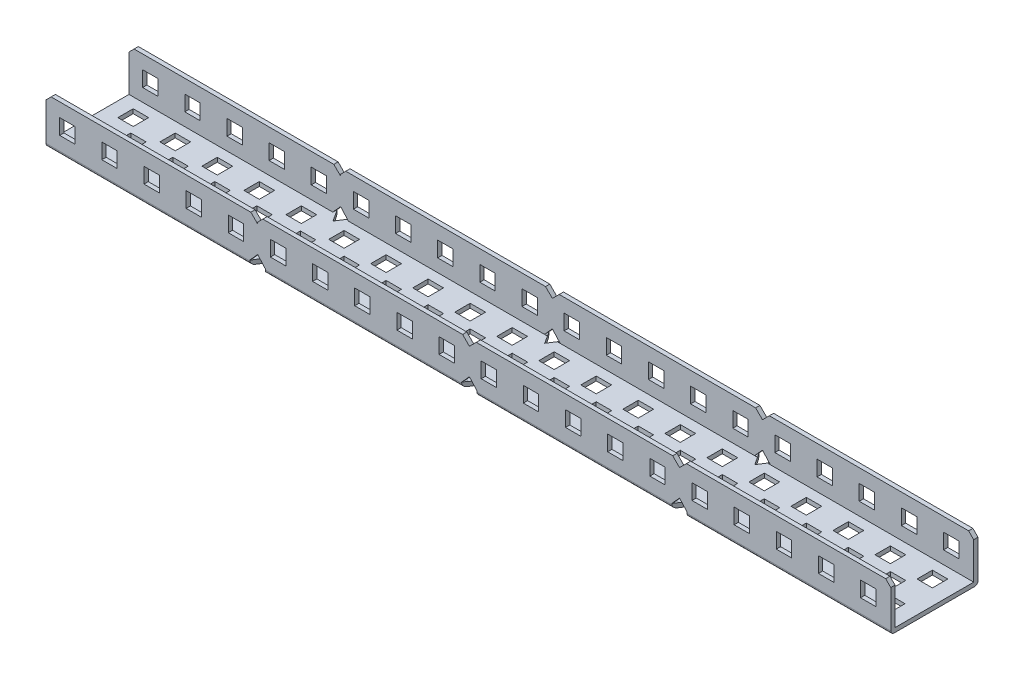
from build123d import *

# Parameters (mm, degrees)
SKETCH1_W           = 191
SKETCH1_H           = 25.5
BOSS_EXTRUDE1_DEPTH = 1.25
SKETCH2_W           = 191
SKETCH2_H           = 1.25
BOSS_EXTRUDE2_DEPTH = 12.25
SKETCH3_W           = 4.5
SKETCH3_H           = 4.5
CUT_EXTRUDE1_DEPTH  = 12.25
CUT_EXTRUDE2_DEPTH  = 1.3
CUT_EXTRUDE4_DEPTH  = 48.3
CUT_EXTRUDE5_DEPTH  = 48.3
FILLET1_R           = 1
SKETCH8_W           = 4.5
SKETCH8_H           = 4.5
BOSS_EXTRUDE3_DEPTH = 1.25
SKETCH9_W           = 2.25
SKETCH9_H           = 4.5
CUT_EXTRUDE6_DEPTH  = 1.25
BOSS_EXTRUDE4_DEPTH = 25.5
SKETCH11_W          = 23
SKETCH11_H          = 12.25
CUT_EXTRUDE7_DEPTH  = 284.5
SKETCH12_W          = 4.5
SKETCH12_H          = 4.5
CUT_EXTRUDE8_DEPTH  = 284.5
CUT_EXTRUDE9_DEPTH  = 284.5
FILLET2_R           = 1
SKETCH14_W          = 5.918571429
SKETCH14_H          = 1
SKETCH14_W_2        = 4.5
SKETCH14_H_2        = 4.5
CUT_EXTRUDE10_DEPTH = 284.5
CUT_EXTRUDE11_DEPTH = 284.5
SKETCH16_W          = 2.581428571
SKETCH16_H          = 4.5
BOSS_EXTRUDE5_DEPTH = 1.25


with BuildPart() as part:
    # Sketch1 → Boss-Extrude1 (new body)
    with BuildSketch(Plane(origin=(0, 0, 0), x_dir=(1, 0, 0), z_dir=(0, 1, 0))):
        with Locations((95.5, 12.75)):
            Rectangle(SKETCH1_W, SKETCH1_H)
    extrude(amount=BOSS_EXTRUDE1_DEPTH)

    # Sketch2 → Boss-Extrude2 (add)
    with BuildSketch(Plane(origin=(0, 1.25, 0), x_dir=(1, 0, 0), z_dir=(0, 1, 0))):
        with Locations((95.5, 24.875)):
            Rectangle(SKETCH2_W, SKETCH2_H)
        with Locations((95.5, 0.625)):
            Rectangle(SKETCH2_W, SKETCH2_H)
    extrude(amount=BOSS_EXTRUDE2_DEPTH)

    # Sketch3 → Cut-Extrude1 (cut)
    with BuildSketch(Plane(origin=(0, 0, 0), x_dir=(-1, 0, 0), z_dir=(0, -1, 0))):
        with Locations((-6.25, 6.5)):
            Rectangle(SKETCH3_W, SKETCH3_H)
        with Locations((-6.25, 19)):
            Rectangle(SKETCH3_W, SKETCH3_H)
        with Locations((-18.535714286, 6.5)):
            Rectangle(SKETCH3_W, SKETCH3_H)
        with Locations((-12.75, 12.5)):
            Rectangle(SKETCH3_W, SKETCH3_H)
        with Locations((-18.535714286, 19)):
            Rectangle(SKETCH3_W, SKETCH3_H)
        with Locations((-25.035714286, 12.5)):
            Rectangle(SKETCH3_W, SKETCH3_H)
        with Locations((-30.821428571, 6.5)):
            Rectangle(SKETCH3_W, SKETCH3_H)
        with Locations((-30.821428571, 19)):
            Rectangle(SKETCH3_W, SKETCH3_H)
        with Locations((-37.321428571, 12.5)):
            Rectangle(SKETCH3_W, SKETCH3_H)
        with Locations((-43.107142857, 6.5)):
            Rectangle(SKETCH3_W, SKETCH3_H)
        with Locations((-43.107142857, 19)):
            Rectangle(SKETCH3_W, SKETCH3_H)
        with Locations((-49.607142857, 12.5)):
            Rectangle(SKETCH3_W, SKETCH3_H)
        with Locations((-55.392857143, 6.5)):
            Rectangle(SKETCH3_W, SKETCH3_H)
        with Locations((-55.392857143, 19)):
            Rectangle(SKETCH3_W, SKETCH3_H)
        with Locations((-61.892857143, 12.5)):
            Rectangle(SKETCH3_W, SKETCH3_H)
        with Locations((-67.678571429, 6.5)):
            Rectangle(SKETCH3_W, SKETCH3_H)
        with Locations((-67.678571429, 19)):
            Rectangle(SKETCH3_W, SKETCH3_H)
        with Locations((-74.178571429, 12.5)):
            Rectangle(SKETCH3_W, SKETCH3_H)
        with Locations((-79.964285714, 6.5)):
            Rectangle(SKETCH3_W, SKETCH3_H)
        with Locations((-79.964285714, 19)):
            Rectangle(SKETCH3_W, SKETCH3_H)
        with Locations((-86.464285714, 12.5)):
            Rectangle(SKETCH3_W, SKETCH3_H)
        with Locations((-92.25, 6.5)):
            Rectangle(SKETCH3_W, SKETCH3_H)
        with Locations((-92.25, 19)):
            Rectangle(SKETCH3_W, SKETCH3_H)
        with Locations((-98.75, 12.5)):
            Rectangle(SKETCH3_W, SKETCH3_H)
        with Locations((-104.535714286, 6.5)):
            Rectangle(SKETCH3_W, SKETCH3_H)
        with Locations((-104.535714286, 19)):
            Rectangle(SKETCH3_W, SKETCH3_H)
        with Locations((-111.035714286, 12.5)):
            Rectangle(SKETCH3_W, SKETCH3_H)
        with Locations((-116.821428571, 6.5)):
            Rectangle(SKETCH3_W, SKETCH3_H)
        with Locations((-116.821428571, 19)):
            Rectangle(SKETCH3_W, SKETCH3_H)
        with Locations((-123.321428571, 12.5)):
            Rectangle(SKETCH3_W, SKETCH3_H)
        with Locations((-129.107142857, 6.5)):
            Rectangle(SKETCH3_W, SKETCH3_H)
        with Locations((-129.107142857, 19)):
            Rectangle(SKETCH3_W, SKETCH3_H)
        with Locations((-135.607142857, 12.5)):
            Rectangle(SKETCH3_W, SKETCH3_H)
        with Locations((-141.392857143, 6.5)):
            Rectangle(SKETCH3_W, SKETCH3_H)
        with Locations((-141.392857143, 19)):
            Rectangle(SKETCH3_W, SKETCH3_H)
        with Locations((-147.892857143, 12.5)):
            Rectangle(SKETCH3_W, SKETCH3_H)
        with Locations((-153.678571429, 6.5)):
            Rectangle(SKETCH3_W, SKETCH3_H)
        with Locations((-153.678571429, 19)):
            Rectangle(SKETCH3_W, SKETCH3_H)
        with Locations((-160.178571429, 12.5)):
            Rectangle(SKETCH3_W, SKETCH3_H)
        with Locations((-165.964285714, 6.5)):
            Rectangle(SKETCH3_W, SKETCH3_H)
        with Locations((-165.964285714, 19)):
            Rectangle(SKETCH3_W, SKETCH3_H)
        with Locations((-172.464285714, 12.5)):
            Rectangle(SKETCH3_W, SKETCH3_H)
        with Locations((-178.25, 6.5)):
            Rectangle(SKETCH3_W, SKETCH3_H)
        with Locations((-178.25, 19)):
            Rectangle(SKETCH3_W, SKETCH3_H)
        with Locations((-184.75, 12.5)):
            Rectangle(SKETCH3_W, SKETCH3_H)
    extrude(amount=-CUT_EXTRUDE1_DEPTH, mode=Mode.SUBTRACT)

    # Sketch4 → Cut-Extrude2 (cut)
    with BuildSketch(Plane.XZ):
        Polygon((61.892857143, -3.5), (59.642857143, 0), (64.142857143, 0), align=None)
        Polygon((123.321428571, -3.5), (121.071428571, 0), (125.571428571, 0), align=None)
        Polygon((121.071428571, -25.5), (125.571428571, -25.5), (123.321428571, -22), align=None)
        Polygon((59.642857143, -25.5), (64.142857143, -25.5), (61.892857143, -22), align=None)
    extrude(amount=-CUT_EXTRUDE2_DEPTH, mode=Mode.SUBTRACT)

    # Sketch6 → Cut-Extrude4 (cut)
    with BuildSketch(Plane(origin=(0, 0, -25.5), x_dir=(-1, 0, 0), z_dir=(0, 0, -1))):
        Polygon((-123.321428571, 3.8), (-121.071428571, 1.3), (-125.571428571, 1.3), align=None)
        Polygon((-61.892857143, 3.8), (-59.642857143, 1.3), (-64.142857143, 1.3), align=None)
        Polygon((-125.321428571, 13.5), (-121.321428571, 13.5), (-123.321428571, 11.5), align=None)
        Polygon((-63.892857143, 13.5), (-59.892857143, 13.5), (-61.892857143, 11.5), align=None)
    extrude(amount=-CUT_EXTRUDE4_DEPTH, mode=Mode.SUBTRACT)

    # Sketch7 → Cut-Extrude5 (cut)
    with BuildSketch(Plane(origin=(0, 0, -25.5), x_dir=(-1, 0, 0), z_dir=(0, 0, -1))):
        Polygon((-191, 13.5), (-191, 12), (-189.5, 13.5), align=None)
        Polygon((-1.5, 13.5), (0, 13.5), (0, 12), align=None)
    extrude(amount=-CUT_EXTRUDE5_DEPTH, mode=Mode.SUBTRACT)

    # Fillet1
    fillet1_edges = [part.edges().sort_by_distance(p)[0] for p in [
        (158.285714286, 0, -25.5),
        (29.821428571, 0, 0),
        (92.607142857, 0, 0),
        (92.607142857, 0, -25.5),
        (29.821428571, 0, -25.5),
        (158.285714286, 0, 0),
    ]]
    fillet(fillet1_edges, radius=FILLET1_R)

    # Sketch8 → Boss-Extrude3 (add)
    with BuildSketch(Plane.XZ):
        Polygon((-2.25, -25.5), (0, -22), (0, -14.75), (-2.25, -14.75), (-2.25, -10.25), (0, -10.25), (0, -3.5), (-2.25, 0), (-61.892857143, 0), (-61.892857143, -25.5), align=None)
        with Locations((-55.642857143, -19)):
            Rectangle(SKETCH8_W, SKETCH8_H, mode=Mode.SUBTRACT)
        with Locations((-43.357142857, -19)):
            Rectangle(SKETCH8_W, SKETCH8_H, mode=Mode.SUBTRACT)
        with Locations((-31.071428571, -19)):
            Rectangle(SKETCH8_W, SKETCH8_H, mode=Mode.SUBTRACT)
        with Locations((-18.785714286, -19)):
            Rectangle(SKETCH8_W, SKETCH8_H, mode=Mode.SUBTRACT)
        with Locations((-6.5, -19)):
            Rectangle(SKETCH8_W, SKETCH8_H, mode=Mode.SUBTRACT)
        with Locations((-49.142857143, -12.5)):
            Rectangle(SKETCH8_W, SKETCH8_H, mode=Mode.SUBTRACT)
        with Locations((-36.857142857, -12.5)):
            Rectangle(SKETCH8_W, SKETCH8_H, mode=Mode.SUBTRACT)
        with Locations((-55.642857143, -6.5)):
            Rectangle(SKETCH8_W, SKETCH8_H, mode=Mode.SUBTRACT)
        with Locations((-43.357142857, -6.5)):
            Rectangle(SKETCH8_W, SKETCH8_H, mode=Mode.SUBTRACT)
        with Locations((-31.071428571, -6.5)):
            Rectangle(SKETCH8_W, SKETCH8_H, mode=Mode.SUBTRACT)
        with Locations((-24.571428571, -12.5)):
            Rectangle(SKETCH8_W, SKETCH8_H, mode=Mode.SUBTRACT)
        with Locations((-12.285714286, -12.5)):
            Rectangle(SKETCH8_W, SKETCH8_H, mode=Mode.SUBTRACT)
        with Locations((-18.785714286, -6.5)):
            Rectangle(SKETCH8_W, SKETCH8_H, mode=Mode.SUBTRACT)
        with Locations((-6.5, -6.5)):
            Rectangle(SKETCH8_W, SKETCH8_H, mode=Mode.SUBTRACT)
    extrude(amount=-BOSS_EXTRUDE3_DEPTH)

    # Sketch9 → Cut-Extrude6 (cut)
    with BuildSketch(Plane.XZ):
        with Locations((1.125, -12.5)):
            Rectangle(SKETCH9_W, SKETCH9_H)
        Polygon((2.25, -25.5), (0, -22), (0, -25.5), align=None)
        Polygon((-2.25, 0), (0, -3.5), (2.25, 0), align=None)
    extrude(amount=-CUT_EXTRUDE6_DEPTH, mode=Mode.SUBTRACT)

    # Sketch10 → Boss-Extrude4 (add)
    with BuildSketch(Plane.XY):
        Polygon((0, 11.5), (-2, 13.5), (-60.392857143, 13.5), (-61.892857143, 12), (-61.892857143, 1.25), (-61.892857143, 0), (-2.25, 0), (-2.25, 1), (-2.25, 1.3), (0, 3.8), align=None)
    extrude(amount=-BOSS_EXTRUDE4_DEPTH)

    # Sketch11 → Cut-Extrude7 (cut)
    with BuildSketch(Plane(origin=(191, 0, 0), x_dir=(0, 0, -1), z_dir=(1, 0, 0))):
        with Locations((12.75, 7.375)):
            Rectangle(SKETCH11_W, SKETCH11_H)
    extrude(amount=-CUT_EXTRUDE7_DEPTH, mode=Mode.SUBTRACT)

    # Sketch12 → Cut-Extrude8 (cut)
    with BuildSketch(Plane.XZ):
        with Locations((55.392857143, -6.5)):
            Rectangle(SKETCH12_W, SKETCH12_H)
        with Locations((49.607142857, -12.5)):
            Rectangle(SKETCH12_W, SKETCH12_H)
        with Locations((43.107142857, -19)):
            Rectangle(SKETCH12_W, SKETCH12_H)
        with Locations((55.392857143, -19)):
            Rectangle(SKETCH12_W, SKETCH12_H)
        with Locations((43.107142857, -6.5)):
            Rectangle(SKETCH12_W, SKETCH12_H)
        with Locations((37.321428571, -12.5)):
            Rectangle(SKETCH12_W, SKETCH12_H)
        with Locations((30.821428571, -6.5)):
            Rectangle(SKETCH12_W, SKETCH12_H)
        with Locations((30.821428571, -19)):
            Rectangle(SKETCH12_W, SKETCH12_H)
        with Locations((25.035714286, -12.5)):
            Rectangle(SKETCH12_W, SKETCH12_H)
        with Locations((18.535714286, -6.5)):
            Rectangle(SKETCH12_W, SKETCH12_H)
        with Locations((18.535714286, -19)):
            Rectangle(SKETCH12_W, SKETCH12_H)
        with Locations((12.75, -12.5)):
            Rectangle(SKETCH12_W, SKETCH12_H)
        with Locations((6.25, -6.5)):
            Rectangle(SKETCH12_W, SKETCH12_H)
        with Locations((6.25, -19)):
            Rectangle(SKETCH12_W, SKETCH12_H)
        with Locations((-6.25, -19)):
            Rectangle(SKETCH12_W, SKETCH12_H)
        with Locations((-6.25, -6.5)):
            Rectangle(SKETCH12_W, SKETCH12_H)
        with Locations((-12.75, -12.5)):
            Rectangle(SKETCH12_W, SKETCH12_H)
        with Locations((-18.535714286, -19)):
            Rectangle(SKETCH12_W, SKETCH12_H)
        with Locations((-18.535714286, -6.5)):
            Rectangle(SKETCH12_W, SKETCH12_H)
        with Locations((-25.035714286, -12.5)):
            Rectangle(SKETCH12_W, SKETCH12_H)
        with Locations((-30.821428571, -19)):
            Rectangle(SKETCH12_W, SKETCH12_H)
        with Locations((-30.821428571, -6.5)):
            Rectangle(SKETCH12_W, SKETCH12_H)
        with Locations((-37.321428571, -12.5)):
            Rectangle(SKETCH12_W, SKETCH12_H)
        with Locations((-43.107142857, -6.5)):
            Rectangle(SKETCH12_W, SKETCH12_H)
        with Locations((-55.392857143, -19)):
            Rectangle(SKETCH12_W, SKETCH12_H)
        with Locations((-43.107142857, -19)):
            Rectangle(SKETCH12_W, SKETCH12_H)
        with Locations((-49.607142857, -12.5)):
            Rectangle(SKETCH12_W, SKETCH12_H)
        with Locations((-55.392857143, -6.5)):
            Rectangle(SKETCH12_W, SKETCH12_H)
    extrude(amount=-CUT_EXTRUDE8_DEPTH, mode=Mode.SUBTRACT)

    # Sketch13 → Cut-Extrude9 (cut)
    with BuildSketch(Plane(origin=(0, 0, -25.5), x_dir=(-1, 0, 0), z_dir=(0, 0, -1))):
        Polygon((0, 3.8), (-2.25, 1.25), (0, 1.25), align=None)
    extrude(amount=-CUT_EXTRUDE9_DEPTH, mode=Mode.SUBTRACT)

    # Fillet2
    fillet2_edges = [part.edges().sort_by_distance(p)[0] for p in [
        (-32.071428571, 0, -25.5),
        (-32.071428571, 0, 0),
    ]]
    fillet(fillet2_edges, radius=FILLET2_R)

    # Sketch14 → Cut-Extrude10 (cut)
    with BuildSketch(Plane.XY):
        Polygon((189.5, 13.5), (185.081428571, 13.5), (185.081428571, 1), (191, 1), (191, 12), align=None)
        with Locations((188.040714286, 0.5)):
            Rectangle(SKETCH14_W, SKETCH14_H)
        with Locations((178.498214286, 7.25)):
            Rectangle(SKETCH14_W_2, SKETCH14_H_2)
        with Locations((166.175, 7.25)):
            Rectangle(SKETCH14_W_2, SKETCH14_H_2)
        with Locations((153.851785714, 7.25)):
            Rectangle(SKETCH14_W_2, SKETCH14_H_2)
        with Locations((141.528571429, 7.25)):
            Rectangle(SKETCH14_W_2, SKETCH14_H_2)
        with Locations((129.205357143, 7.25)):
            Rectangle(SKETCH14_W_2, SKETCH14_H_2)
        with Locations((116.882142857, 7.25)):
            Rectangle(SKETCH14_W_2, SKETCH14_H_2)
        with Locations((104.558928571, 7.25)):
            Rectangle(SKETCH14_W_2, SKETCH14_H_2)
        with Locations((92.235714286, 7.25)):
            Rectangle(SKETCH14_W_2, SKETCH14_H_2)
        with Locations((79.9125, 7.25)):
            Rectangle(SKETCH14_W_2, SKETCH14_H_2)
        with Locations((67.589285714, 7.25)):
            Rectangle(SKETCH14_W_2, SKETCH14_H_2)
        with Locations((55.266071429, 7.25)):
            Rectangle(SKETCH14_W_2, SKETCH14_H_2)
        with Locations((42.942857143, 7.25)):
            Rectangle(SKETCH14_W_2, SKETCH14_H_2)
        with Locations((30.619642857, 7.25)):
            Rectangle(SKETCH14_W_2, SKETCH14_H_2)
        with Locations((18.296428571, 7.25)):
            Rectangle(SKETCH14_W_2, SKETCH14_H_2)
        with Locations((5.973214286, 7.25)):
            Rectangle(SKETCH14_W_2, SKETCH14_H_2)
        with Locations((-6.35, 7.25)):
            Rectangle(SKETCH14_W_2, SKETCH14_H_2)
        with Locations((-18.673214286, 7.25)):
            Rectangle(SKETCH14_W_2, SKETCH14_H_2)
        with Locations((-30.996428571, 7.25)):
            Rectangle(SKETCH14_W_2, SKETCH14_H_2)
        with Locations((-43.319642857, 7.25)):
            Rectangle(SKETCH14_W_2, SKETCH14_H_2)
        with Locations((-55.642857143, 7.25)):
            Rectangle(SKETCH14_W_2, SKETCH14_H_2)
    extrude(amount=-CUT_EXTRUDE10_DEPTH, mode=Mode.SUBTRACT)

    # Sketch15 → Cut-Extrude11 (cut)
    with BuildSketch(Plane.XY):
        Polygon((185.081428571, 13.5), (185.081428571, 12), (183.581428571, 13.5), align=None)
    extrude(amount=-CUT_EXTRUDE11_DEPTH, mode=Mode.SUBTRACT)

    # Sketch16 → Boss-Extrude5 (add)
    with BuildSketch(Plane.XZ):
        with Locations((183.790714286, -12.5)):
            Rectangle(SKETCH16_W, SKETCH16_H)
    extrude(amount=-BOSS_EXTRUDE5_DEPTH)


solid = part.part
